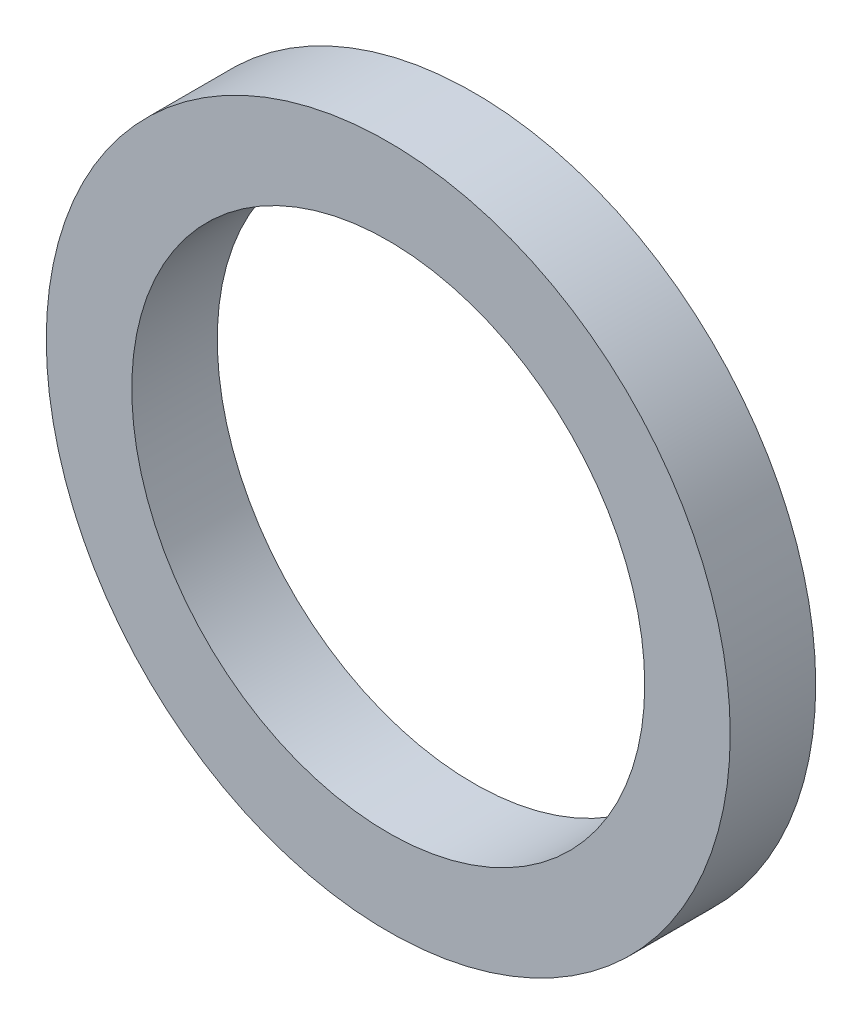
from build123d import *

# Parameters (mm, degrees)
SKETCH1_R           = 12.7
SKETCH1_R_2         = 9.525
BOSS_EXTRUDE1_DEPTH = 3.175


with BuildPart() as part:
    # Sketch1 → Boss-Extrude1 (new body)
    with BuildSketch(Plane.XY):
        Circle(SKETCH1_R)
        Circle(SKETCH1_R_2, mode=Mode.SUBTRACT)
    extrude(amount=BOSS_EXTRUDE1_DEPTH)


solid = part.part
